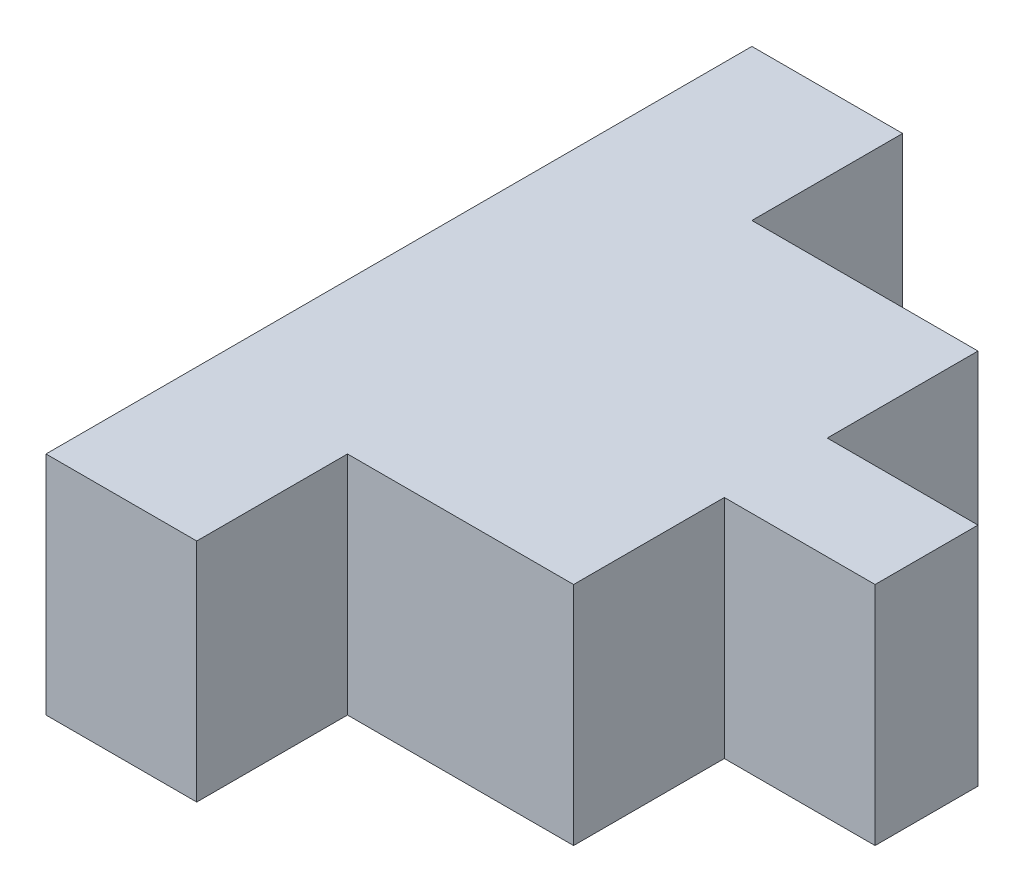
from build123d import *

# Parameters (mm, degrees)
BOSS_EXTRUDE1_DEPTH = 76.2


with BuildPart() as part:
    # Sketch3 → Boss-Extrude1 (new body)
    with BuildSketch(Plane(origin=(0, 0, 0), x_dir=(1, 0, 0), z_dir=(0, 1, 0))):
        Polygon((0, 0), (50.8, 0), (50.8, 50.8), (127, 50.8), (127, 101.6), (177.8, 101.6), (177.8, 136.285247541), (127, 136.285247541), (127, 187.085247541), (50.8, 187.085247541), (50.8, 237.885247541), (0, 237.885247541), align=None)
    extrude(amount=BOSS_EXTRUDE1_DEPTH)


solid = part.part
